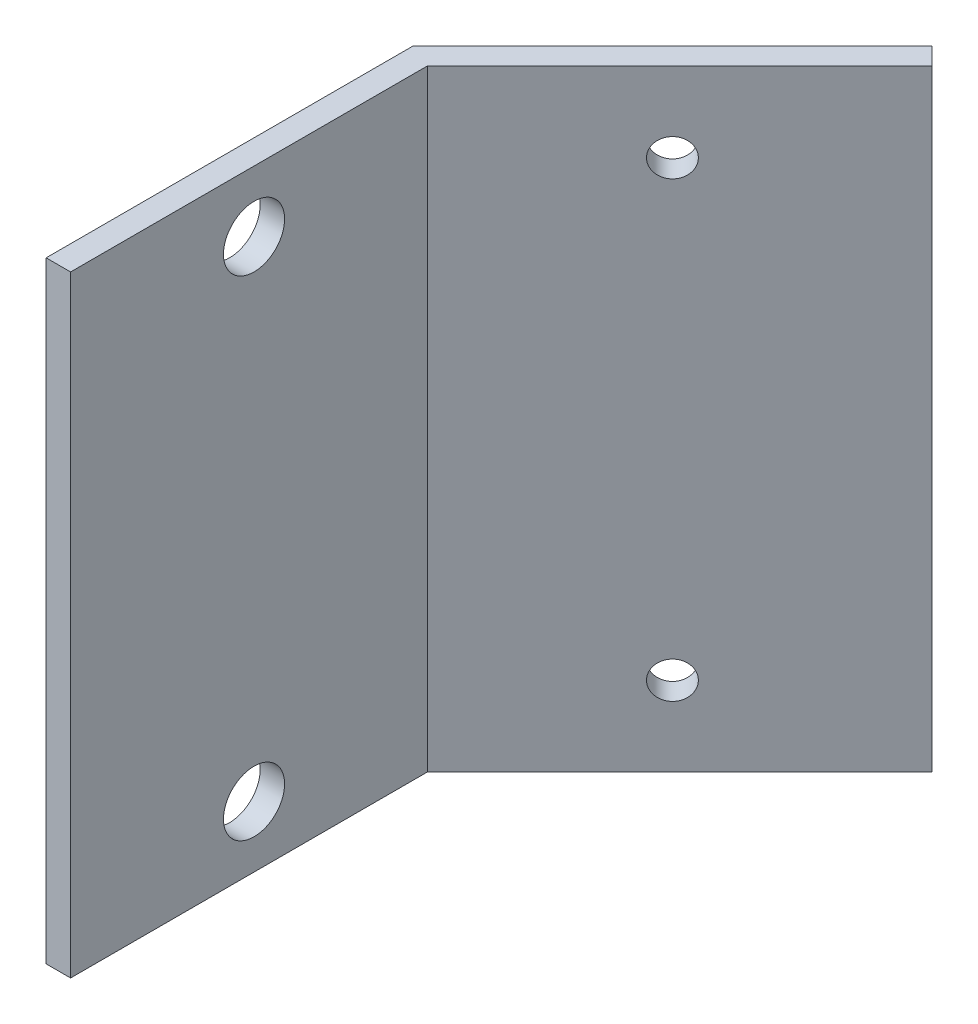
from build123d import *

# Parameters (mm, degrees)
EXTRUSION1_DEPTH = 50
EXTRUSION2_REACH = 24.627
ESQUISSE3_R      = 2.5
EXTRUSION3_REACH = 39.213
ESQUISSE4_R      = 1.5


with BuildPart() as part:
    # Esquisse1 → Extrusion1 (new body)
    with BuildSketch(Plane(origin=(0, 0, 0), x_dir=(1, 0, 0), z_dir=(0, 1, 0))):
        Polygon((0, 0), (0, 30), (21.213203436, 51.213203436), (22.627416998, 49.798989873), (2, 29.171572875), (2, 0), align=None)
    extrude(amount=EXTRUSION1_DEPTH)

    # Esquisse3 → Extrusion2 (cut, up to next)
    with BuildSketch(Plane.ZY, mode=Mode.PRIVATE) as extrusion2_sk1:
        with Locations((-15, 5)):
            Circle(ESQUISSE3_R)
    extrusion2_tool1 = extrude(extrusion2_sk1.sketch, amount=-EXTRUSION2_REACH, mode=Mode.PRIVATE) & part.part
    add(extrusion2_tool1.solids().sort_by_distance((0, 5, -15))[0], mode=Mode.SUBTRACT)
    # Esquisse3 → Extrusion2 (cut, up to next)
    with BuildSketch(Plane.ZY, mode=Mode.PRIVATE) as extrusion2_sk2:
        with Locations((-15, 45)):
            Circle(ESQUISSE3_R)
    extrusion2_tool2 = extrude(extrusion2_sk2.sketch, amount=-EXTRUSION2_REACH, mode=Mode.PRIVATE) & part.part
    add(extrusion2_tool2.solids().sort_by_distance((0, 45, -15))[0], mode=Mode.SUBTRACT)

    # Esquisse4 → Extrusion3 (cut, up to next)
    with BuildSketch(Plane(origin=(-15, 0, -15), x_dir=(-0.707106781, 0, 0.707106781), z_dir=(-0.707106781, 0, -0.707106781)), mode=Mode.PRIVATE) as extrusion3_sk1:
        with Locations((-36.213203436, 43.5)):
            Circle(ESQUISSE4_R)
    extrusion3_tool1 = extrude(extrusion3_sk1.sketch, amount=-EXTRUSION3_REACH, mode=Mode.PRIVATE) & part.part
    add(extrusion3_tool1.solids().sort_by_distance((10.606602, 43.5, -40.606602))[0], mode=Mode.SUBTRACT)
    # Esquisse4 → Extrusion3 (cut, up to next)
    with BuildSketch(Plane(origin=(-15, 0, -15), x_dir=(-0.707106781, 0, 0.707106781), z_dir=(-0.707106781, 0, -0.707106781)), mode=Mode.PRIVATE) as extrusion3_sk2:
        with Locations((-36.213203436, 6.5)):
            Circle(ESQUISSE4_R)
    extrusion3_tool2 = extrude(extrusion3_sk2.sketch, amount=-EXTRUSION3_REACH, mode=Mode.PRIVATE) & part.part
    add(extrusion3_tool2.solids().sort_by_distance((10.606602, 6.5, -40.606602))[0], mode=Mode.SUBTRACT)


solid = part.part
